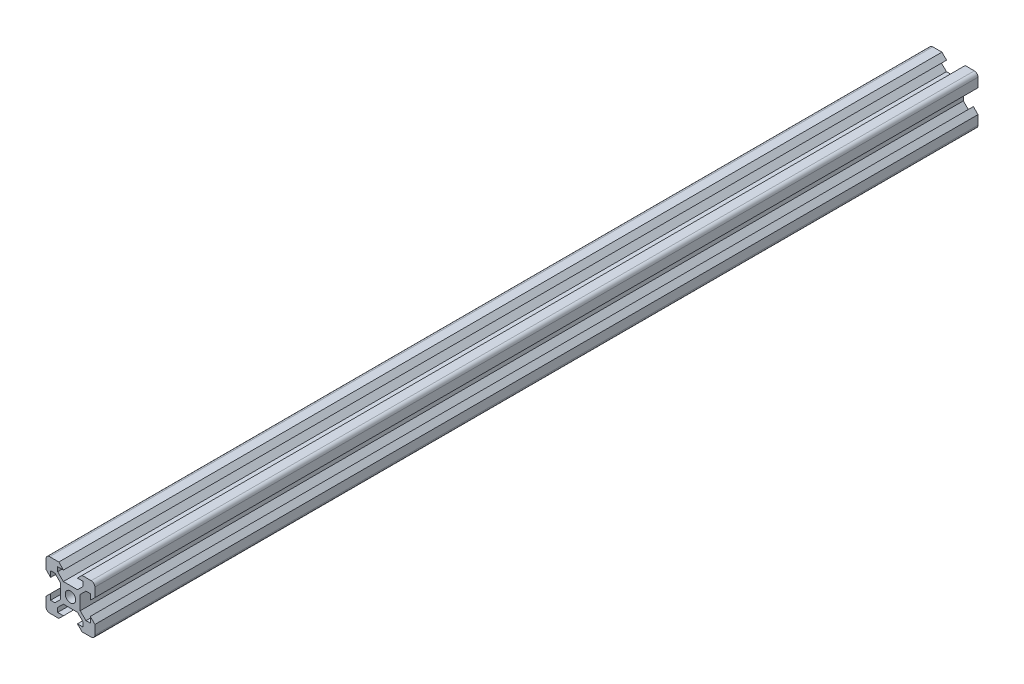
from build123d import *

# Parameters (mm, degrees)
SKETCH1_R           = 2.125
BOSS_EXTRUDE1_DEPTH = 361.19


with BuildPart() as part:
    # Sketch1 → Boss-Extrude1 (new body)
    with BuildSketch(Plane.XY):
        with BuildLine():
            Line((8.1, 5.225), (8.1, 2.85))
            Line((8.1, 2.85), (10, 4.75))
            Line((10, 4.75), (10, 8.5))
            ThreePointArc((10, 8.5), (9.560660172, 9.560660172), (8.5, 10))
            Line((8.5, 10), (4.75, 10))
            Line((4.75, 10), (2.85, 8.1))
            Line((2.85, 8.1), (5.225, 8.1))
            Line((5.225, 8.1), (5.225, 6.325))
            Line((5.225, 6.325), (2.9, 4))
            Line((2.9, 4), (-2.9, 4))
            Line((-2.9, 4), (-5.225, 6.325))
            Line((-5.225, 6.325), (-5.225, 8.1))
            Line((-5.225, 8.1), (-2.85, 8.1))
            Line((-2.85, 8.1), (-4.75, 10))
            Line((-4.75, 10), (-8.5, 10))
            ThreePointArc((-8.5, 10), (-9.560660172, 9.560660172), (-10, 8.5))
            Line((-10, 8.5), (-10, 4.75))
            Line((-10, 4.75), (-8.1, 2.85))
            Line((-8.1, 2.85), (-8.1, 5.225))
            Line((-8.1, 5.225), (-6.325, 5.225))
            Line((-6.325, 5.225), (-4, 2.9))
            Line((-4, 2.9), (-4, -2.9))
            Line((-4, -2.9), (-6.325, -5.225))
            Line((-6.325, -5.225), (-8.1, -5.225))
            Line((-8.1, -5.225), (-8.1, -2.85))
            Line((-8.1, -2.85), (-10, -4.75))
            Line((-10, -4.75), (-10, -8.5))
            ThreePointArc((-10, -8.5), (-9.560660172, -9.560660172), (-8.5, -10))
            Line((-8.5, -10), (-4.75, -10))
            Line((-4.75, -10), (-2.85, -8.1))
            Line((-2.85, -8.1), (-5.225, -8.1))
            Line((-5.225, -8.1), (-5.225, -6.325))
            Line((-5.225, -6.325), (-2.9, -4))
            Line((-2.9, -4), (2.9, -4))
            Line((2.9, -4), (5.225, -6.325))
            Line((5.225, -6.325), (5.225, -8.1))
            Line((5.225, -8.1), (2.85, -8.1))
            Line((2.85, -8.1), (4.75, -10))
            Line((4.75, -10), (8.5, -10))
            ThreePointArc((8.5, -10), (9.560660172, -9.560660172), (10, -8.5))
            Line((10, -8.5), (10, -4.75))
            Line((10, -4.75), (8.1, -2.85))
            Line((8.1, -2.85), (8.1, -5.225))
            Line((8.1, -5.225), (6.325, -5.225))
            Line((6.325, -5.225), (4, -2.9))
            Line((4, -2.9), (4, 2.9))
            Line((4, 2.9), (6.325, 5.225))
            Line((6.325, 5.225), (8.1, 5.225))
        make_face()
        Circle(SKETCH1_R, mode=Mode.SUBTRACT)
    extrude(amount=BOSS_EXTRUDE1_DEPTH)


solid = part.part
